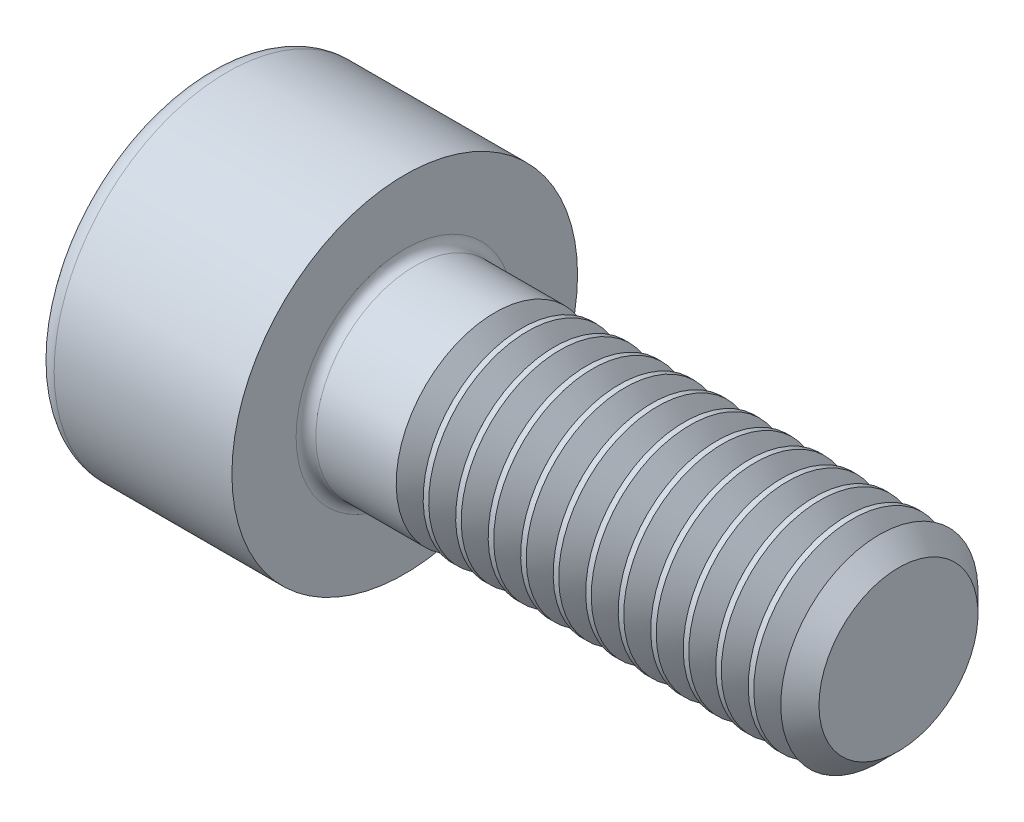
from build123d import *

# Parameters (mm, degrees)
FILLET1_R       = 0.2
FILLET2_R       = 0.4
HEX_2_DEPTH     = 2
THDSCHPAT_COUNT = 12
THDSCHPAT_PITCH = 0.658333333


with BuildPart() as part:
    # BodySke → Base-Revolve (revolve)
    with BuildSketch(Plane.XY, mode=Mode.PRIVATE) as base_revolve_sk:
        Polygon((0, 0), (0, 3.5), (4, 3.5), (4, 2), (13.61, 2), (14, 1.61), (14, 0), align=None)
    revolve(base_revolve_sk.sketch.rotate(Axis((-31.75, 0, 0), (1, 0, 0)), 90), axis=Axis((-31.75, 0, 0), (1, 0, 0)))  # turned: the seam where the file's is

    # Fillet1
    fillet1_edges = [part.edges().sort_by_distance(p)[0] for p in [
        (4, 0, -2),
    ]]
    fillet(fillet1_edges, radius=FILLET1_R)

    # Fillet2
    fillet2_edges = [part.edges().sort_by_distance(p)[0] for p in [
        (0, 0, -3.5),
    ]]
    fillet(fillet2_edges, radius=FILLET2_R)

    # Sketch2 → Hex-PreBroach (revolve, cut)
    with BuildSketch(Plane.XY, mode=Mode.PRIVATE) as hex_prebroach_sk:
        Polygon((0, 1.51), (2, 1.51), (2.871798906, 0), (0, 0), align=None)
    revolve(hex_prebroach_sk.sketch.rotate(Axis((0, 0, 0), (1, 0, 0)), 90), axis=Axis((0, 0, 0), (1, 0, 0)), mode=Mode.SUBTRACT)  # turned: the seam where the file's is

    # Sketch3 → Hex 2 (cut)
    with BuildSketch(Plane(origin=(0, 0, 0), x_dir=(0, 0.5, 0.866025404), z_dir=(-1, 0, 0))):
        Polygon((0.871798906, 1.51), (-0.871798906, 1.51), (-1.743597813, 0), (-0.871798906, -1.51), (0.871798906, -1.51), (1.743597813, 0), align=None)
    extrude(amount=-HEX_2_DEPTH, mode=Mode.SUBTRACT)

    # ThdSchSke → ThreadSchematic (revolve, cut)
    with BuildSketch(Plane.XY, mode=Mode.PRIVATE) as threadschematic_sk:
        Polygon((6.1, -1.61), (5.82691906, -2), (5.82691906, -2.5), (6.37308094, -2.5), (6.37308094, -2), align=None)
    threadschematic = revolve(threadschematic_sk.sketch.rotate(Axis((-3.175, 0, 0), (1, 0, 0)), 270), axis=Axis((-3.175, 0, 0), (1, 0, 0)), mode=Mode.SUBTRACT)  # turned: the seam where the file's is

    # ThdSchPat: ThreadSchematic ×12
    with Locations(*[(i * THDSCHPAT_PITCH, 0, 0) for i in range(1, THDSCHPAT_COUNT)]):
        add(threadschematic, mode=Mode.SUBTRACT)


solid = part.part
